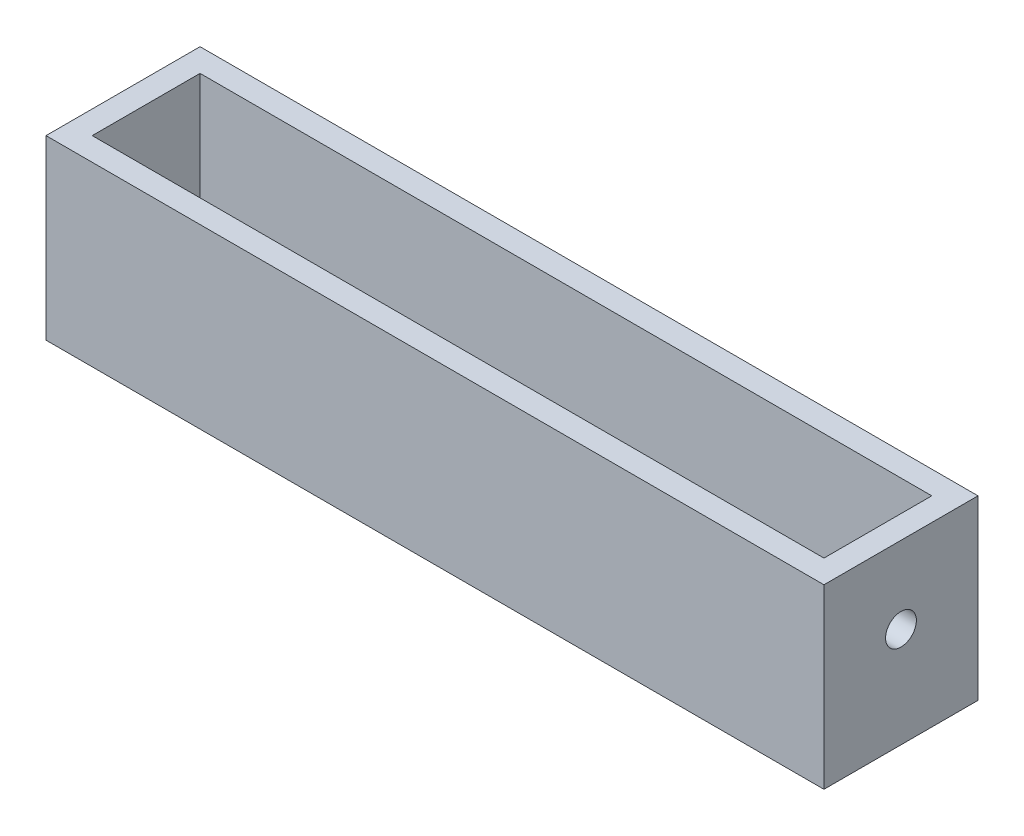
from build123d import *

# Parameters (mm, degrees)
SKETCH_1_W      = 101
SKETCH_1_H      = 20
SKETCH_1_R      = 4
EXTRUDE_1_DEPTH = 3
EXTRUDE_2_DEPTH = 3
SKETCH_3_W      = 20
SKETCH_3_H      = 20
SKETCH_3_R      = 2
EXTRUDE_3_DEPTH = 3
SKETCH_4_W      = 95
SKETCH_4_H      = 20
EXTRUDE_4_DEPTH = 3
SKETCH_5_W      = 95
SKETCH_5_H      = 20
EXTRUDE_5_DEPTH = 3


with BuildPart() as part:
    # 草图1 → 凸台-拉伸1 (new body)
    with BuildSketch(Plane(origin=(0, 0, 0), x_dir=(1, 0, 0), z_dir=(0, 1, 0))):
        Rectangle(SKETCH_1_W, SKETCH_1_H)
        with Locations((-37.5, 0)):
            Circle(SKETCH_1_R, mode=Mode.SUBTRACT)
        with Locations((37.5, 0)):
            Circle(SKETCH_1_R, mode=Mode.SUBTRACT)
    extrude(amount=EXTRUDE_1_DEPTH)

    # 草图2 → 凸台-拉伸2 (add)
    with BuildSketch(Plane.ZY.offset(50.5)):
        Polygon((-10, 23), (-10, 3), (10, 3), (10, 23), (0, 23), align=None)
        with BuildLine():
            ThreePointArc((2, 13), (-1.414213562, 11.585786438), (0, 15))
            ThreePointArc((0, 15), (1.414213562, 14.414213562), (2, 13))
        make_face(mode=Mode.SUBTRACT)
    extrude(amount=-EXTRUDE_2_DEPTH)

    # 草图3 → 凸台-拉伸3 (add)
    with BuildSketch(Plane(origin=(50.5, 0, 0), x_dir=(0, 0, -1), z_dir=(1, 0, 0))):
        with Locations((0, 13)):
            Rectangle(SKETCH_3_W, SKETCH_3_H)
        with Locations((0, 13)):
            Circle(SKETCH_3_R, mode=Mode.SUBTRACT)
    extrude(amount=-EXTRUDE_3_DEPTH)

    # 草图4 → 凸台-拉伸4 (add)
    with BuildSketch(Plane.XY.offset(10)):
        with Locations((0, 13)):
            Rectangle(SKETCH_4_W, SKETCH_4_H)
    extrude(amount=-EXTRUDE_4_DEPTH)

    # 草图5 → 凸台-拉伸5 (add)
    with BuildSketch(Plane(origin=(0, 0, -10), x_dir=(-1, 0, 0), z_dir=(0, 0, -1))):
        with Locations((0, 13)):
            Rectangle(SKETCH_5_W, SKETCH_5_H)
    extrude(amount=-EXTRUDE_5_DEPTH)


solid = part.part
